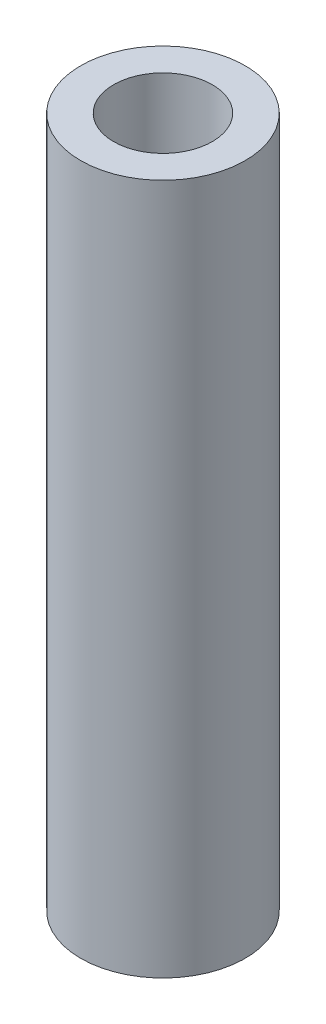
from build123d import *

# Parameters (mm, degrees)
SKETCH1_R           = 15.875
SKETCH1_R_2         = 9.525
BOSS_EXTRUDE1_DEPTH = 133.35


with BuildPart() as part:
    # Sketch1 → Boss-Extrude1 (new body)
    with BuildSketch(Plane(origin=(0, 0, 0), x_dir=(1, 0, 0), z_dir=(0, 1, 0))):
        Circle(SKETCH1_R)
        Circle(SKETCH1_R_2, mode=Mode.SUBTRACT)
    extrude(amount=BOSS_EXTRUDE1_DEPTH)


solid = part.part
